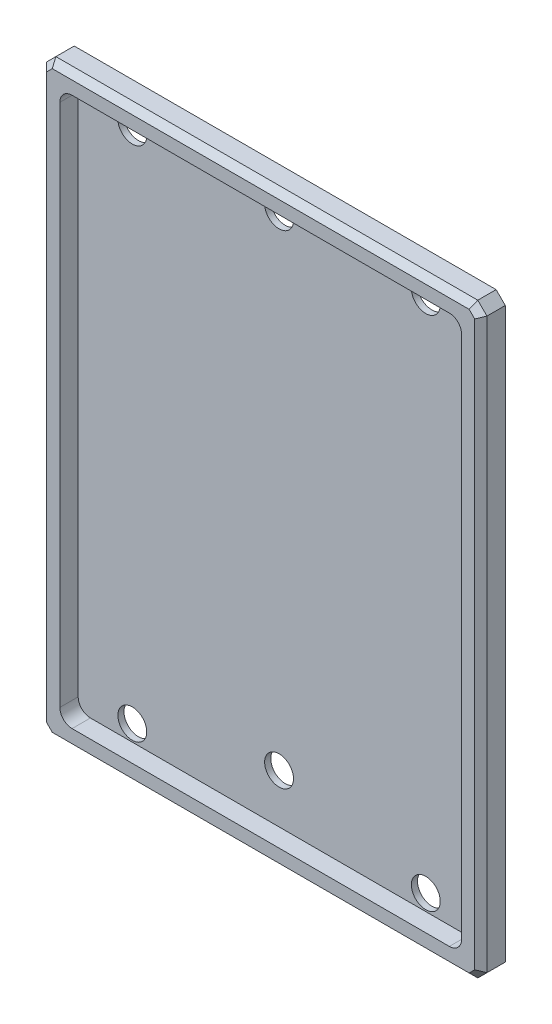
from build123d import *

# Parameters (mm, degrees)
SKETCH1_W                 = 228.6
SKETCH1_H                 = 304.8
BOSS_EXTRUDE1_DEPTH       = 12.7
CUT_EXTRUDE1_DEPTH        = 9.525
SKETCH4_R                 = 7.5
CUT_EXTRUDE2_DEPTH        = 4.175
M4X0_7_TAPPED_HOLE1_D     = 3.3
M4X0_7_TAPPED_HOLE1_DEPTH = 8
M4X0_7_TAPPED_HOLE1_TIP   = 0.991420021
CHAMFER1_SIZE             = 4.7625
CHAMFER2_SIZE             = 3.175


with BuildPart() as part:
    # Sketch1 → Boss-Extrude1 (new body)
    with BuildSketch(Plane.XY):
        Rectangle(SKETCH1_W, SKETCH1_H)
    extrude(amount=BOSS_EXTRUDE1_DEPTH)

    # Sketch2 → Cut-Extrude1 (cut)
    with BuildSketch(Plane.XY.offset(12.7)):
        with BuildLine():
            Line((97.95, -142.4), (-97.95, -142.4))
            ThreePointArc((-97.95, -142.4), (-102.440128061, -140.540128061), (-104.3, -136.05))
            Line((-104.3, -136.05), (-104.3, 136.05))
            ThreePointArc((-104.3, 136.05), (-102.440128061, 140.540128061), (-97.95, 142.4))
            Line((-97.95, 142.4), (97.95, 142.4))
            ThreePointArc((97.95, 142.4), (102.440128061, 140.540128061), (104.3, 136.05))
            Line((104.3, 136.05), (104.3, -136.05))
            ThreePointArc((104.3, -136.05), (102.440128061, -140.540128061), (97.95, -142.4))
        make_face()
    extrude(amount=-CUT_EXTRUDE1_DEPTH, mode=Mode.SUBTRACT)

    # Sketch4 → Cut-Extrude2 (cut, through all)
    with BuildSketch(Plane.XY.offset(3.175)):
        with Locations((-76.2, 134.05)):
            Circle(SKETCH4_R)
        with Locations((76.2, 134.05)):
            Circle(SKETCH4_R)
        with Locations((-76.2, -134.05)):
            Circle(SKETCH4_R)
        with Locations((76.2, -134.05)):
            Circle(SKETCH4_R)
        with Locations((0, 134.05)):
            Circle(SKETCH4_R)
        with Locations((0, -117)):
            Circle(SKETCH4_R)
    extrude(amount=-CUT_EXTRUDE2_DEPTH, mode=Mode.SUBTRACT)

    # M4x0.7 Tapped Hole1
    with Locations(Plane(origin=(0, 0, 0), x_dir=(-1, 0, 0), z_dir=(0, 0, -1))):
        with Locations((-109.3, -102.4), (-109.3, 0), (-109.3, 113.6)):
            Hole(M4X0_7_TAPPED_HOLE1_D / 2, depth=M4X0_7_TAPPED_HOLE1_DEPTH)
            with Locations((0, 0, -(M4X0_7_TAPPED_HOLE1_DEPTH + M4X0_7_TAPPED_HOLE1_TIP / 2))):  # 118° drill point
                Cone(0, M4X0_7_TAPPED_HOLE1_D / 2, M4X0_7_TAPPED_HOLE1_TIP, mode=Mode.SUBTRACT)

    # Chamfer1
    chamfer1_edges = [part.edges().sort_by_distance(p)[0] for p in [
        (-114.3, 152.4, 6.35),
        (114.3, 152.4, 6.35),
        (114.3, -152.4, 6.35),
        (-114.3, -152.4, 6.35),
    ]]
    chamfer(chamfer1_edges, length=CHAMFER1_SIZE)

    # Chamfer2
    chamfer2_edges = [part.edges().sort_by_distance(p)[0] for p in [
        (0, -152.4, 12.7),
        (-114.3, 0, 12.7),
        (114.3, 0, 12.7),
        (0, 152.4, 12.7),
        (111.91875, 150.01875, 12.7),
        (-111.91875, 150.01875, 12.7),
        (111.91875, -150.01875, 12.7),
        (-111.91875, -150.01875, 12.7),
    ]]
    chamfer(chamfer2_edges, length=CHAMFER2_SIZE)


solid = part.part
